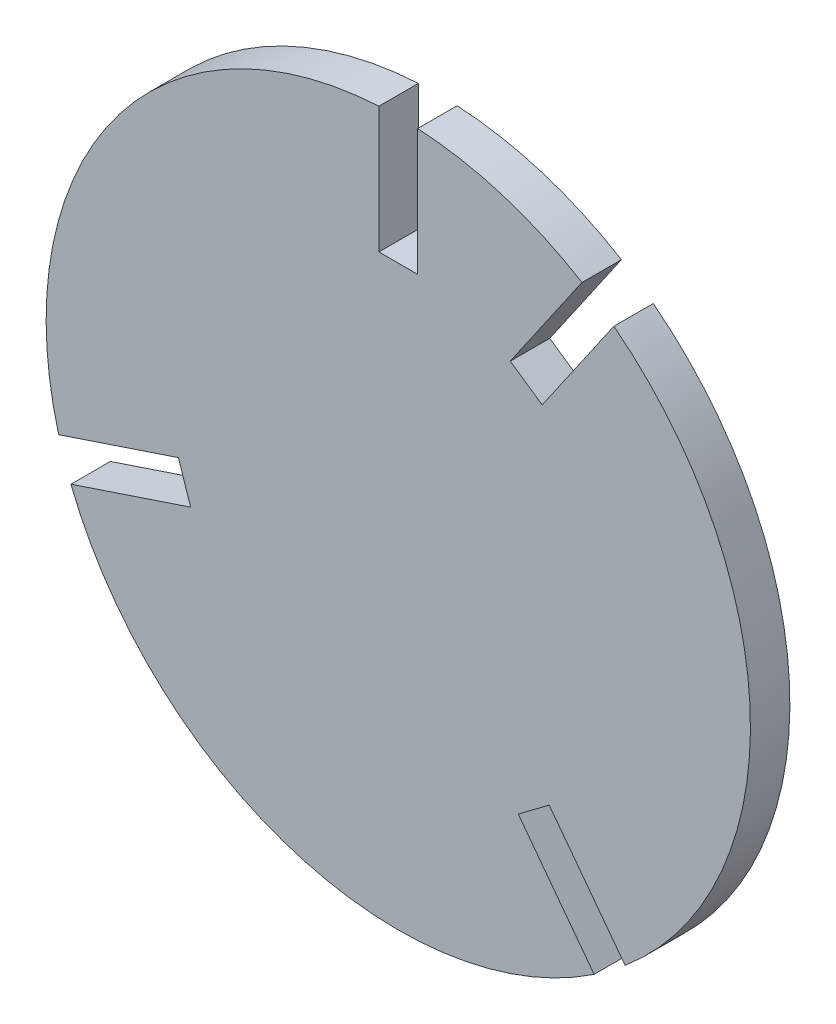
from build123d import *

# Parameters (mm, degrees)
CROQUIS1_R              = 25
SALIENTE_EXTRUIR1_DEPTH = 2.8
CROQUIS2_W              = 2.75
CROQUIS2_H              = 18
CORTAR_EXTRUIR1_DEPTH   = 3.8
MATRIZC2_COUNT          = 4
MATRIZC2_ANGLE          = 325.41


with BuildPart() as part:
    # Croquis1 → Saliente-Extruir1 (new body)
    with BuildSketch(Plane.XY):
        Circle(CROQUIS1_R)
    extrude(amount=SALIENTE_EXTRUIR1_DEPTH)

    # Croquis2 → Cortar-Extruir1 (cut, through all)
    with BuildSketch(Plane.XY):
        with Locations((0, 25)):
            Rectangle(CROQUIS2_W, CROQUIS2_H)
    cortar_extruir1 = extrude(amount=CORTAR_EXTRUIR1_DEPTH, mode=Mode.SUBTRACT)

    # MatrizC2: Cortar-Extruir1 ×4 about axis
    matrizc2_axis = Axis((0, 0, 0), (0, 0, 1))
    for i in range(1, MATRIZC2_COUNT):
        add(cortar_extruir1.rotate(matrizc2_axis, i * MATRIZC2_ANGLE / (MATRIZC2_COUNT - 1)), mode=Mode.SUBTRACT)


solid = part.part
